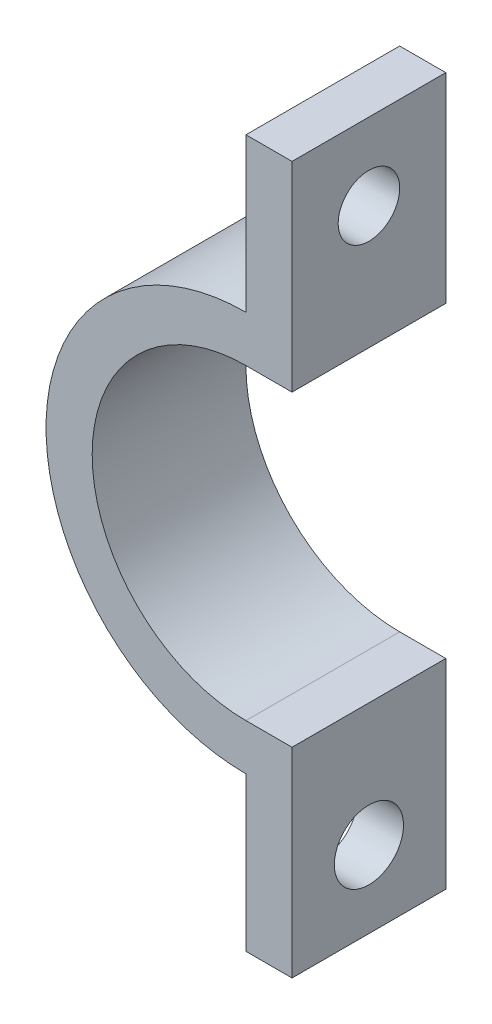
from build123d import *

# Parameters (mm, degrees)
EXTRUDE_1_DEPTH     = 10
SKETCH_3_R          = 2
CUT_EXTRUDE_2_DEPTH = 4
SKETCH_4_R          = 2.25
CUT_EXTRUDE_3_DEPTH = 3.2


with BuildPart() as part:
    # 草图1 → 凸台-拉伸1 (new body)
    with BuildSketch(Plane.XY):
        with BuildLine():
            Line((0, 23), (3, 23))
            Line((3, 23), (3, 10))
            Line((3, 10), (0, 10))
            ThreePointArc((0, 10), (-10, 0), (0, -10))
            Line((0, -10), (3, -10))
            Line((3, -10), (3, -23))
            Line((3, -23), (0, -23))
            Line((0, -23), (0, -13))
            ThreePointArc((0, -13), (-13, 0), (0, 13))
            Line((0, 13), (0, 23))
        make_face()
    extrude(amount=EXTRUDE_1_DEPTH)

    # 草图3 → 切除-拉伸2 (cut, through all)
    with BuildSketch(Plane.ZY):
        with Locations((5, 18)):
            Circle(SKETCH_3_R)
    extrude(amount=-CUT_EXTRUDE_2_DEPTH, mode=Mode.SUBTRACT)

    # 草图4 → 切除-拉伸3 (cut)
    with BuildSketch(Plane.ZY):
        with Locations((5, -18)):
            Circle(SKETCH_4_R)
    extrude(amount=-CUT_EXTRUDE_3_DEPTH, mode=Mode.SUBTRACT)


solid = part.part
